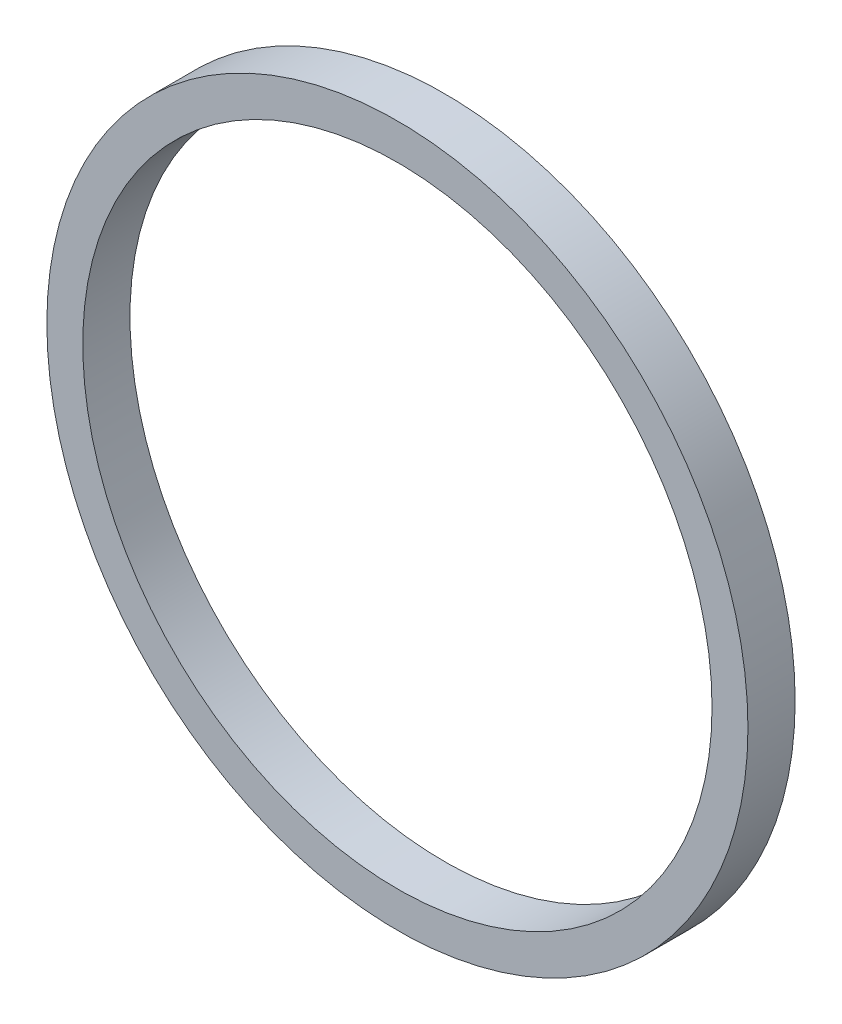
from build123d import *

# Parameters (mm, degrees)
SKETCH1_R           = 141.5
SKETCH1_R_2         = 127
BOSS_EXTRUDE1_DEPTH = 19.05


with BuildPart() as part:
    # Sketch1 → Boss-Extrude1 (new body)
    with BuildSketch(Plane.XY):
        Circle(SKETCH1_R)
        Circle(SKETCH1_R_2, mode=Mode.SUBTRACT)
    extrude(amount=BOSS_EXTRUDE1_DEPTH)


solid = part.part
